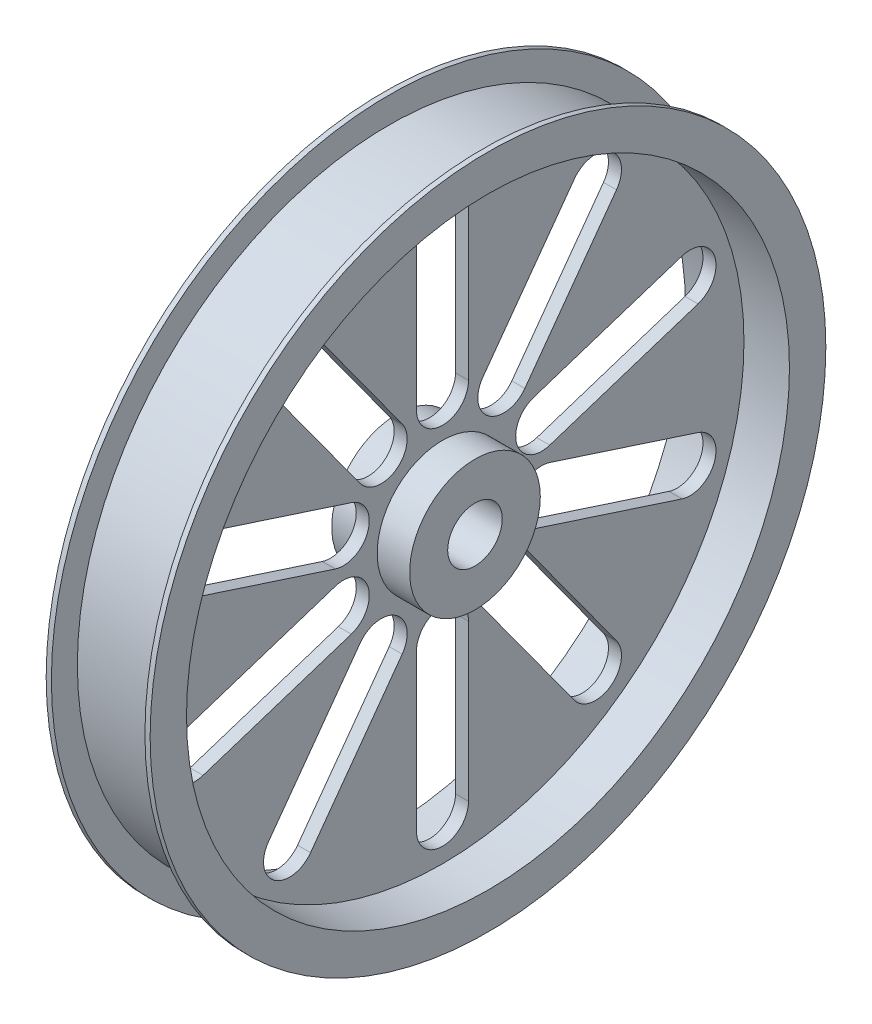
from build123d import *

# Parameters (mm, degrees)
SKETCH3_R                = 13.335
CUT_EXTRUDE1_DEPTH       = 7.35
CUT_EXTRUDE1_DEPTH_BACK  = 45.45
CUT_EXTRUDE10_DEPTH      = 23.225
CUT_EXTRUDE10_DEPTH_BACK = 29.575


with BuildPart() as part:
    # Sketch2 → Revolve2 (revolve)
    with BuildSketch(Plane.XY):
        Polygon((22.86, 152.4), (-22.86, 152.4), (-22.86, 165.1), (-25.4, 165.1), (-25.4, 147.32), (-3.175, 147.32), (-3.175, 31.92334197), (-19.05, 31.92334197), (-19.05, 0), (19.05, 0), (19.05, 31.92334197), (3.175, 31.92334197), (3.175, 147.32), (25.4, 147.32), (25.4, 165.1), (22.86, 165.1), align=None)
    revolve(axis=Axis((217.873654092, 0, 0), (-1, 0, 0)))

    # Sketch3 → Cut-Extrude1 (cut, two sides)
    with BuildSketch(Plane.ZY.offset(19.05)) as cut_extrude1_sk:
        Circle(SKETCH3_R)
    extrude(amount=CUT_EXTRUDE1_DEPTH, mode=Mode.SUBTRACT)
    extrude(cut_extrude1_sk.sketch, amount=-CUT_EXTRUDE1_DEPTH_BACK, mode=Mode.SUBTRACT)

    # Sketch4 → Cut-Extrude10 (cut, two sides)
    with BuildSketch(Plane.ZY.offset(3.175)) as cut_extrude10_sk:
        with BuildLine():
            Line((12.7, 127.17334197), (12.7, 50.97334197))
            ThreePointArc((12.7, 50.97334197), (0, 38.27334197), (-12.7, 50.97334197))
            Line((-12.7, 50.97334197), (-12.7, 127.17334197))
            ThreePointArc((-12.7, 127.17334197), (0, 139.87334197), (12.7, 127.17334197))
        make_face()
        with BuildLine():
            Line((64.476099066, 110.350267589), (19.686862842, 48.703172618))
            ThreePointArc((19.686862842, 48.703172618), (22.496505966, 30.963784085), (40.235894499, 33.77342721))
            Line((40.235894499, 33.77342721), (85.025130723, 95.420522181))
            ThreePointArc((85.025130723, 95.420522181), (82.215487599, 113.159910714), (64.476099066, 110.350267589))
        make_face()
        with BuildLine():
            Line((117.024519751, 51.377141657), (44.55401321, 27.830046686))
            ThreePointArc((44.55401321, 27.830046686), (36.400111281, 11.8271131), (52.403044867, 3.673211172))
            Line((52.403044867, 3.673211172), (124.873551408, 27.220306143))
            ThreePointArc((124.873551408, 27.220306143), (133.027453337, 43.223239729), (117.024519751, 51.377141657))
        make_face()
        with BuildLine():
            Line((124.873551408, -27.220306143), (52.403044867, -3.673211172))
            ThreePointArc((52.403044867, -3.673211172), (36.400111281, -11.8271131), (44.55401321, -27.830046686))
            Line((44.55401321, -27.830046686), (117.024519751, -51.377141657))
            ThreePointArc((117.024519751, -51.377141657), (133.027453337, -43.223239729), (124.873551408, -27.220306143))
        make_face()
        with BuildLine():
            Line((85.025130723, -95.420522181), (40.235894499, -33.77342721))
            ThreePointArc((40.235894499, -33.77342721), (22.496505966, -30.963784085), (19.686862842, -48.703172618))
            Line((19.686862842, -48.703172618), (64.476099066, -110.350267589))
            ThreePointArc((64.476099066, -110.350267589), (82.215487599, -113.159910714), (85.025130723, -95.420522181))
        make_face()
        with BuildLine():
            Line((12.7, -127.17334197), (12.7, -50.97334197))
            ThreePointArc((12.7, -50.97334197), (0, -38.27334197), (-12.7, -50.97334197))
            Line((-12.7, -50.97334197), (-12.7, -127.17334197))
            ThreePointArc((-12.7, -127.17334197), (0, -139.87334197), (12.7, -127.17334197))
        make_face()
        with BuildLine():
            Line((-64.476099066, -110.350267589), (-19.686862842, -48.703172618))
            ThreePointArc((-19.686862842, -48.703172618), (-22.496505966, -30.963784085), (-40.235894499, -33.77342721))
            Line((-40.235894499, -33.77342721), (-85.025130723, -95.420522181))
            ThreePointArc((-85.025130723, -95.420522181), (-82.215487599, -113.159910714), (-64.476099066, -110.350267589))
        make_face()
        with BuildLine():
            Line((-117.024519751, -51.377141657), (-44.55401321, -27.830046686))
            ThreePointArc((-44.55401321, -27.830046686), (-36.400111281, -11.8271131), (-52.403044867, -3.673211172))
            Line((-52.403044867, -3.673211172), (-124.873551408, -27.220306143))
            ThreePointArc((-124.873551408, -27.220306143), (-133.027453337, -43.223239729), (-117.024519751, -51.377141657))
        make_face()
        with BuildLine():
            Line((-124.873551408, 27.220306143), (-52.403044867, 3.673211172))
            ThreePointArc((-52.403044867, 3.673211172), (-36.400111281, 11.8271131), (-44.55401321, 27.830046686))
            Line((-44.55401321, 27.830046686), (-117.024519751, 51.377141657))
            ThreePointArc((-117.024519751, 51.377141657), (-133.027453337, 43.223239729), (-124.873551408, 27.220306143))
        make_face()
        with BuildLine():
            Line((-85.025130723, 95.420522181), (-40.235894499, 33.77342721))
            ThreePointArc((-40.235894499, 33.77342721), (-22.496505966, 30.963784085), (-19.686862842, 48.703172618))
            Line((-19.686862842, 48.703172618), (-64.476099066, 110.350267589))
            ThreePointArc((-64.476099066, 110.350267589), (-82.215487599, 113.159910714), (-85.025130723, 95.420522181))
        make_face()
    extrude(amount=CUT_EXTRUDE10_DEPTH, mode=Mode.SUBTRACT)
    extrude(cut_extrude10_sk.sketch, amount=-CUT_EXTRUDE10_DEPTH_BACK, mode=Mode.SUBTRACT)


solid = part.part
